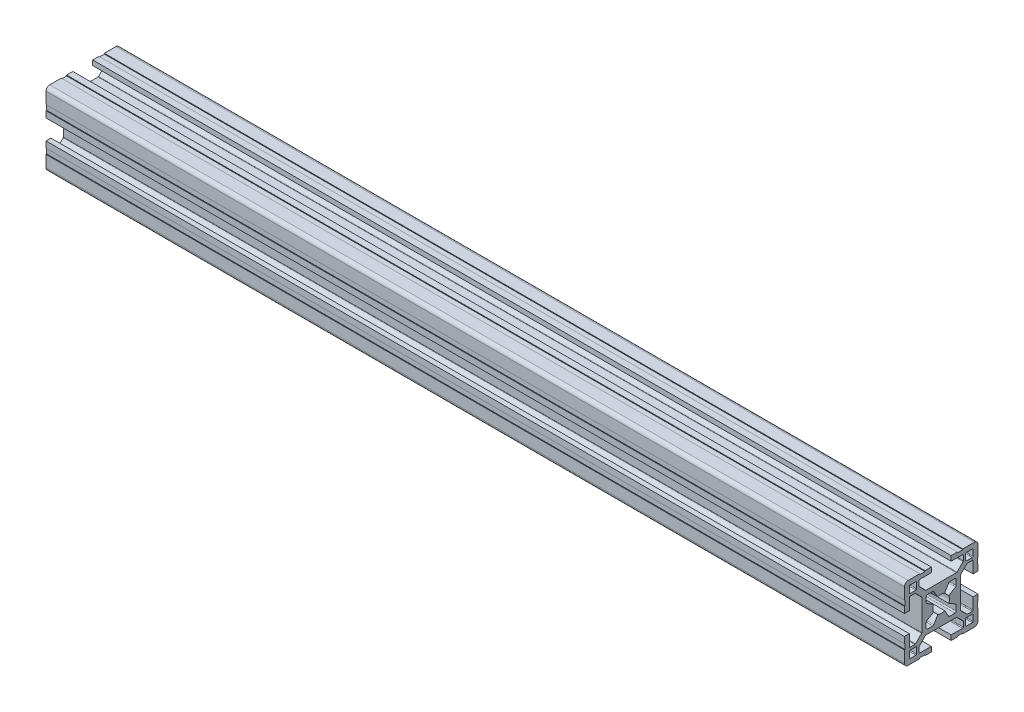
from build123d import *

# Parameters (mm, degrees)
QUADRADO_PF30_11_PERFIL_3030_CENTRO_M8_DEPTH = 350


with BuildPart() as part:
    # Sketch1 → Quadrado PF30-11 - PERFIL 3030 CENTRO M8(1) (new body)
    with BuildSketch(Plane.YZ):
        with BuildLine():
            Line((14.999995923, 6.599996803), (14.699995923, 6.599996803))
            Line((14.699995923, 6.599996803), (14.699995923, 8.799996803))
            Line((14.699995923, 8.799996803), (14.999995923, 8.799996803))
            Line((14.999995923, 8.799996803), (14.999995923, 13.499995825))
            ThreePointArc((14.999995923, 13.499995825), (14.560656066, 14.560656066), (13.499995825, 14.999995923))
            Line((13.499995825, 14.999995923), (8.799996818, 14.999995923))
            Line((8.799996818, 14.999995923), (8.799996818, 14.699995923))
            Line((8.799996818, 14.699995923), (6.599996818, 14.699995923))
            Line((6.599996818, 14.699995923), (6.599996818, 14.999995923))
            Line((6.599996818, 14.999995923), (4.0499987, 14.999995923))
            Line((4.0499987, 14.999995923), (4.0499987, 12.999995366))
            Line((4.0499987, 12.999995366), (8.699997649, 12.999995366))
            ThreePointArc((8.699997649, 12.999995366), (8.912129683, 12.9121274), (8.999997649, 12.699995366))
            Line((8.999997649, 12.699995366), (8.999997649, 10.679894006))
            ThreePointArc((8.999997649, 10.679894006), (8.977161511, 10.565088981), (8.912129691, 10.467761979))
            Line((8.912129691, 10.467761979), (6.432230191, 7.987862303))
            ThreePointArc((6.432230191, 7.987862303), (6.334903184, 7.922830472), (6.220098149, 7.89999433))
            Line((6.220098149, 7.89999433), (-6.220098149, 7.89999433))
            ThreePointArc((-6.220098149, 7.89999433), (-6.334903184, 7.922830472), (-6.432230191, 7.987862303))
            Line((-6.432230191, 7.987862303), (-8.912129691, 10.467761979))
            ThreePointArc((-8.912129691, 10.467761979), (-8.977161511, 10.565088981), (-8.999997649, 10.679894006))
            Line((-8.999997649, 10.679894006), (-8.999997649, 12.699995366))
            ThreePointArc((-8.999997649, 12.699995366), (-8.912129683, 12.9121274), (-8.699997649, 12.999995366))
            Line((-8.699997649, 12.999995366), (-4.0499987, 12.999995366))
            Line((-4.0499987, 12.999995366), (-4.0499987, 14.999995923))
            Line((-4.0499987, 14.999995923), (-6.599996818, 14.999995923))
            Line((-6.599996818, 14.999995923), (-6.599996818, 14.699995923))
            Line((-6.599996818, 14.699995923), (-8.799996818, 14.699995923))
            Line((-8.799996818, 14.699995923), (-8.799996818, 14.999995923))
            Line((-8.799996818, 14.999995923), (-13.499995825, 14.999995923))
            ThreePointArc((-13.499995825, 14.999995923), (-14.560656066, 14.560656066), (-14.999995923, 13.499995825))
            Line((-14.999995923, 13.499995825), (-14.999995923, 8.799996803))
            Line((-14.999995923, 8.799996803), (-14.699995923, 8.799996803))
            Line((-14.699995923, 8.799996803), (-14.699995923, 6.599996803))
            Line((-14.699995923, 6.599996803), (-14.999995923, 6.599996803))
            Line((-14.999995923, 6.599996803), (-14.999995923, 4.0499987))
            Line((-14.999995923, 4.0499987), (-12.999995366, 4.0499987))
            Line((-12.999995366, 4.0499987), (-12.999995366, 8.699997649))
            ThreePointArc((-12.999995366, 8.699997649), (-12.9121274, 8.912129683), (-12.699995366, 8.999997649))
            Line((-12.699995366, 8.999997649), (-10.679894006, 8.999997649))
            ThreePointArc((-10.679894006, 8.999997649), (-10.565088981, 8.977161511), (-10.467761979, 8.912129691))
            Line((-10.467761979, 8.912129691), (-7.987862303, 6.432230191))
            ThreePointArc((-7.987862303, 6.432230191), (-7.922830472, 6.334903184), (-7.89999433, 6.220098149))
            Line((-7.89999433, 6.220098149), (-7.89999433, -6.220098149))
            ThreePointArc((-7.89999433, -6.220098149), (-7.922830472, -6.334903184), (-7.987862303, -6.432230191))
            Line((-7.987862303, -6.432230191), (-10.467761979, -8.912129691))
            ThreePointArc((-10.467761979, -8.912129691), (-10.565088981, -8.977161511), (-10.679894006, -8.999997649))
            Line((-10.679894006, -8.999997649), (-12.699995366, -8.999997649))
            ThreePointArc((-12.699995366, -8.999997649), (-12.9121274, -8.912129683), (-12.999995366, -8.699997649))
            Line((-12.999995366, -8.699997649), (-12.999995366, -4.0499987))
            Line((-12.999995366, -4.0499987), (-14.999995923, -4.0499987))
            Line((-14.999995923, -4.0499987), (-14.999995923, -6.599996803))
            Line((-14.999995923, -6.599996803), (-14.699995923, -6.599996803))
            Line((-14.699995923, -6.599996803), (-14.699995923, -8.799996803))
            Line((-14.699995923, -8.799996803), (-14.999995923, -8.799996803))
            Line((-14.999995923, -8.799996803), (-14.999995923, -13.499995825))
            ThreePointArc((-14.999995923, -13.499995825), (-14.560656066, -14.560656066), (-13.499995825, -14.999995923))
            Line((-13.499995825, -14.999995923), (-8.799996818, -14.999995923))
            Line((-8.799996818, -14.999995923), (-8.799996818, -14.699995923))
            Line((-8.799996818, -14.699995923), (-6.599996818, -14.699995923))
            Line((-6.599996818, -14.699995923), (-6.599996818, -14.999995923))
            Line((-6.599996818, -14.999995923), (-4.0499987, -14.999995923))
            Line((-4.0499987, -14.999995923), (-4.0499987, -12.999995366))
            Line((-4.0499987, -12.999995366), (-8.699997649, -12.999995366))
            ThreePointArc((-8.699997649, -12.999995366), (-8.912129683, -12.9121274), (-8.999997649, -12.699995366))
            Line((-8.999997649, -12.699995366), (-8.999997649, -10.679894006))
            ThreePointArc((-8.999997649, -10.679894006), (-8.977161511, -10.565088981), (-8.912129691, -10.467761979))
            Line((-8.912129691, -10.467761979), (-6.432230191, -7.987862303))
            ThreePointArc((-6.432230191, -7.987862303), (-6.334903184, -7.922830472), (-6.220098149, -7.89999433))
            Line((-6.220098149, -7.89999433), (6.220098149, -7.89999433))
            ThreePointArc((6.220098149, -7.89999433), (6.334903184, -7.922830472), (6.432230191, -7.987862303))
            Line((6.432230191, -7.987862303), (8.912129691, -10.467761979))
            ThreePointArc((8.912129691, -10.467761979), (8.977161511, -10.565088981), (8.999997649, -10.679894006))
            Line((8.999997649, -10.679894006), (8.999997649, -12.699995366))
            ThreePointArc((8.999997649, -12.699995366), (8.912129683, -12.9121274), (8.699997649, -12.999995366))
            Line((8.699997649, -12.999995366), (4.0499987, -12.999995366))
            Line((4.0499987, -12.999995366), (4.0499987, -14.999995923))
            Line((4.0499987, -14.999995923), (6.599996818, -14.999995923))
            Line((6.599996818, -14.999995923), (6.599996818, -14.699995923))
            Line((6.599996818, -14.699995923), (8.799996818, -14.699995923))
            Line((8.799996818, -14.699995923), (8.799996818, -14.999995923))
            Line((8.799996818, -14.999995923), (13.499995825, -14.999995923))
            ThreePointArc((13.499995825, -14.999995923), (14.560656066, -14.560656066), (14.999995923, -13.499995825))
            Line((14.999995923, -13.499995825), (14.999995923, -8.799996803))
            Line((14.999995923, -8.799996803), (14.699995923, -8.799996803))
            Line((14.699995923, -8.799996803), (14.699995923, -6.599996803))
            Line((14.699995923, -6.599996803), (14.999995923, -6.599996803))
            Line((14.999995923, -6.599996803), (14.999995923, -4.0499987))
            Line((14.999995923, -4.0499987), (12.999995366, -4.0499987))
            Line((12.999995366, -4.0499987), (12.999995366, -8.699997649))
            ThreePointArc((12.999995366, -8.699997649), (12.9121274, -8.912129683), (12.699995366, -8.999997649))
            Line((12.699995366, -8.999997649), (10.679894006, -8.999997649))
            ThreePointArc((10.679894006, -8.999997649), (10.565088981, -8.977161511), (10.467761979, -8.912129691))
            Line((10.467761979, -8.912129691), (7.987862303, -6.432230191))
            ThreePointArc((7.987862303, -6.432230191), (7.922830472, -6.334903184), (7.89999433, -6.220098149))
            Line((7.89999433, -6.220098149), (7.89999433, 6.220098149))
            ThreePointArc((7.89999433, 6.220098149), (7.922830472, 6.334903184), (7.987862303, 6.432230191))
            Line((7.987862303, 6.432230191), (10.467761979, 8.912129691))
            ThreePointArc((10.467761979, 8.912129691), (10.565088981, 8.977161511), (10.679894006, 8.999997649))
            Line((10.679894006, 8.999997649), (12.699995366, 8.999997649))
            ThreePointArc((12.699995366, 8.999997649), (12.9121274, 8.912129683), (12.999995366, 8.699997649))
            Line((12.999995366, 8.699997649), (12.999995366, 4.0499987))
            Line((12.999995366, 4.0499987), (14.999995923, 4.0499987))
            Line((14.999995923, 4.0499987), (14.999995923, 6.599996803))
        make_face()
        with BuildLine():
            Line((-6.1, -3.425408784), (-6.1, -5.6))
            ThreePointArc((-6.1, -5.6), (-5.953553391, -5.953553391), (-5.6, -6.1))
            Line((-5.6, -6.1), (-3.425408784, -6.1))
            ThreePointArc((-3.425408784, -6.1), (-3.175408784, -6.033012702), (-2.992396082, -5.85))
            Line((-2.992396082, -5.85), (-1.402974441, -3.097040962))
            ThreePointArc((-1.402974441, -3.097040962), (0, -3.4), (1.402974441, -3.097040962))
            Line((1.402974441, -3.097040962), (2.992396082, -5.85))
            ThreePointArc((2.992396082, -5.85), (3.175408784, -6.033012702), (3.425408784, -6.1))
            Line((3.425408784, -6.1), (5.6, -6.1))
            ThreePointArc((5.6, -6.1), (5.953553391, -5.953553391), (6.1, -5.6))
            Line((6.1, -5.6), (6.1, -3.425408784))
            ThreePointArc((6.1, -3.425408784), (6.033012702, -3.175408784), (5.85, -2.992396082))
            Line((5.85, -2.992396082), (3.097040962, -1.402974441))
            ThreePointArc((3.097040962, -1.402974441), (3.4, 0), (3.097040962, 1.402974441))
            Line((3.097040962, 1.402974441), (5.85, 2.992396082))
            ThreePointArc((5.85, 2.992396082), (6.033012702, 3.175408784), (6.1, 3.425408784))
            Line((6.1, 3.425408784), (6.1, 5.6))
            ThreePointArc((6.1, 5.6), (5.953553391, 5.953553391), (5.6, 6.1))
            Line((5.6, 6.1), (3.425408784, 6.1))
            ThreePointArc((3.425408784, 6.1), (3.175408784, 6.033012702), (2.992396082, 5.85))
            Line((2.992396082, 5.85), (1.402974441, 3.097040962))
            ThreePointArc((1.402974441, 3.097040962), (0, 3.4), (-1.402974441, 3.097040962))
            Line((-1.402974441, 3.097040962), (-2.992396082, 5.85))
            ThreePointArc((-2.992396082, 5.85), (-3.175408784, 6.033012702), (-3.425408784, 6.1))
            Line((-3.425408784, 6.1), (-5.6, 6.1))
            ThreePointArc((-5.6, 6.1), (-5.953553391, 5.953553391), (-6.1, 5.6))
            Line((-6.1, 5.6), (-6.1, 3.425408784))
            ThreePointArc((-6.1, 3.425408784), (-6.033012702, 3.175408784), (-5.85, 2.992396082))
            Line((-5.85, 2.992396082), (-3.097040962, 1.402974441))
            ThreePointArc((-3.097040962, 1.402974441), (-3.4, 0), (-3.097040962, -1.402974441))
            Line((-3.097040962, -1.402974441), (-5.85, -2.992396082))
            ThreePointArc((-5.85, -2.992396082), (-6.033012702, -3.175408784), (-6.1, -3.425408784))
        make_face(mode=Mode.SUBTRACT)
        with BuildLine():
            Line((9.999995366, 12.699997649), (9.999995366, 10.299997649))
            ThreePointArc((9.999995366, 10.299997649), (10.087863331, 10.087865615), (10.299995366, 9.999997649))
            Line((10.299995366, 9.999997649), (12.699995366, 9.999997649))
            ThreePointArc((12.699995366, 9.999997649), (12.9121274, 10.087865615), (12.999995366, 10.299997649))
            Line((12.999995366, 10.299997649), (12.999995366, 12.699997649))
            ThreePointArc((12.999995366, 12.699997649), (12.9121274, 12.912129683), (12.699995366, 12.999997649))
            Line((12.699995366, 12.999997649), (10.299995366, 12.999997649))
            ThreePointArc((10.299995366, 12.999997649), (10.087863331, 12.912129683), (9.999995366, 12.699997649))
        make_face(mode=Mode.SUBTRACT)
        with BuildLine():
            Line((12.999995366, -12.699997649), (12.999995366, -10.299997649))
            ThreePointArc((12.999995366, -10.299997649), (12.9121274, -10.087865615), (12.699995366, -9.999997649))
            Line((12.699995366, -9.999997649), (10.299995366, -9.999997649))
            ThreePointArc((10.299995366, -9.999997649), (10.087863331, -10.087865615), (9.999995366, -10.299997649))
            Line((9.999995366, -10.299997649), (9.999995366, -12.699997649))
            ThreePointArc((9.999995366, -12.699997649), (10.087863331, -12.912129683), (10.299995366, -12.999997649))
            Line((10.299995366, -12.999997649), (12.699995366, -12.999997649))
            ThreePointArc((12.699995366, -12.999997649), (12.9121274, -12.912129683), (12.999995366, -12.699997649))
        make_face(mode=Mode.SUBTRACT)
        with BuildLine():
            Line((-10.299995366, -9.999997649), (-12.699995366, -9.999997649))
            ThreePointArc((-12.699995366, -9.999997649), (-12.9121274, -10.087865615), (-12.999995366, -10.299997649))
            Line((-12.999995366, -10.299997649), (-12.999995366, -12.699997649))
            ThreePointArc((-12.999995366, -12.699997649), (-12.9121274, -12.912129683), (-12.699995366, -12.999997649))
            Line((-12.699995366, -12.999997649), (-10.299995366, -12.999997649))
            ThreePointArc((-10.299995366, -12.999997649), (-10.087863331, -12.912129683), (-9.999995366, -12.699997649))
            Line((-9.999995366, -12.699997649), (-9.999995366, -10.299997649))
            ThreePointArc((-9.999995366, -10.299997649), (-10.087863331, -10.087865615), (-10.299995366, -9.999997649))
        make_face(mode=Mode.SUBTRACT)
        with BuildLine():
            Line((-12.999995366, 12.699997649), (-12.999995366, 10.299997649))
            ThreePointArc((-12.999995366, 10.299997649), (-12.9121274, 10.087865615), (-12.699995366, 9.999997649))
            Line((-12.699995366, 9.999997649), (-10.299995366, 9.999997649))
            ThreePointArc((-10.299995366, 9.999997649), (-10.087863331, 10.087865615), (-9.999995366, 10.299997649))
            Line((-9.999995366, 10.299997649), (-9.999995366, 12.699997649))
            ThreePointArc((-9.999995366, 12.699997649), (-10.087863331, 12.912129683), (-10.299995366, 12.999997649))
            Line((-10.299995366, 12.999997649), (-12.699995366, 12.999997649))
            ThreePointArc((-12.699995366, 12.999997649), (-12.9121274, 12.912129683), (-12.999995366, 12.699997649))
        make_face(mode=Mode.SUBTRACT)
    extrude(amount=QUADRADO_PF30_11_PERFIL_3030_CENTRO_M8_DEPTH)


solid = part.part
